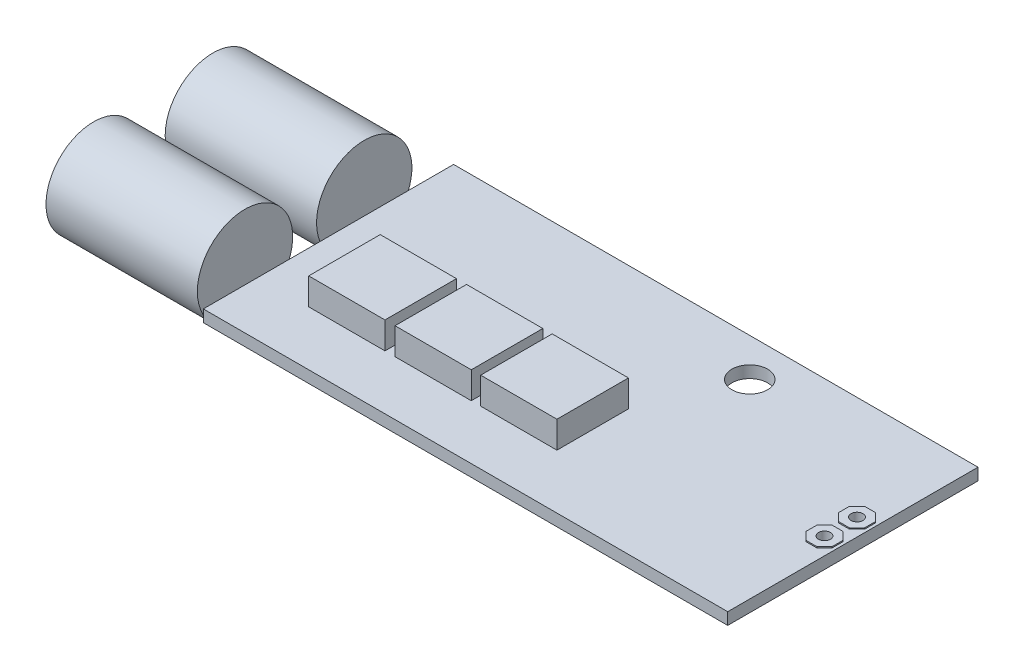
from build123d import *

# Parameters (mm, degrees)
SKETCH_1_W               = 44
SKETCH_1_H               = 21
EXTRUDE_1_DEPTH          = 1
EXTRUDE_3_DEPTH          = 0.1
SKETCH_2_R               = 1.5
SKETCH_2_R_2             = 0.5
CUT_EXTRUDE_1_DEPTH      = 1
CUT_EXTRUDE_1_DEPTH_BACK = 1
SKETCH_3_W               = 6.4
SKETCH_3_H               = 6
EXTRUDE_2_DEPTH          = 2.25
EXTRUDE_2_DEPTH_BACK     = 3.25
EXTRUDE_START            = 2
SKETCH_5_R               = 4
EXTRUDE_4_DEPTH          = 12.7
EXTRUDE_4_2_DEPTH        = 12.7


with BuildPart() as part:
    # Эскиз1 → Бобышка-Вытянуть1 (new body)
    with BuildSketch(Plane(origin=(0, 0, 0), x_dir=(1, 0, 0), z_dir=(0, 1, 0))):
        with Locations((22, -10.5)):
            Rectangle(SKETCH_1_W, SKETCH_1_H)
    extrude(amount=EXTRUDE_1_DEPTH)

    # Эскиз4 → Бобышка-Вытянуть3 (add)
    with BuildSketch(Plane(origin=(0, 1, 0), x_dir=(1, 0, 0), z_dir=(0, 1, 0))):
        Polygon((43.75, -8.344365081), (43.105634919, -7.7), (42.194365081, -7.7), (41.55, -8.344365081), (41.55, -9.255634919), (42.194365081, -9.9), (43.105634919, -9.9), (43.75, -9.255634919), align=None)
        Polygon((41.55, -11.074365081), (41.55, -11.985634919), (42.194365081, -12.63), (43.105634919, -12.63), (43.75, -11.985634919), (43.75, -11.074365081), (43.105634919, -10.43), (42.194365081, -10.43), align=None)
    extrude(amount=EXTRUDE_3_DEPTH)

    # Эскиз2 → Вырез-Вытянуть1 (cut, two sides)
    with BuildSketch(Plane(origin=(0, 1, 0), x_dir=(1, 0, 0), z_dir=(0, 1, 0))) as cut_extrude_1_sk:
        with Locations(Location((28.05, -3.2, 0), (0, 0, 270))):  # turned: the seam where the file's is
            Circle(SKETCH_2_R)
        with Locations(Location((42.65, -8.8, 0), (0, 0, 270))):  # turned: the seam where the file's is
            Circle(SKETCH_2_R_2)
        with Locations(Location((42.65, -11.53, 0), (0, 0, 270))):  # turned: the seam where the file's is
            Circle(SKETCH_2_R_2)
    extrude(amount=CUT_EXTRUDE_1_DEPTH, mode=Mode.SUBTRACT)
    extrude(cut_extrude_1_sk.sketch, amount=-CUT_EXTRUDE_1_DEPTH_BACK, mode=Mode.SUBTRACT)

    # Эскиз3 → Бобышка-Вытянуть2 (add, two sides)
    with BuildSketch(Plane(origin=(0, 1, 0), x_dir=(1, 0, 0), z_dir=(0, 1, 0))) as extrude_2_sk:
        with Locations((7.471, -13.429)):
            Rectangle(SKETCH_3_W, SKETCH_3_H)
        with Locations((14.714, -13.429)):
            Rectangle(SKETCH_3_W, SKETCH_3_H)
        with Locations((21.9, -13.429)):
            Rectangle(SKETCH_3_W, SKETCH_3_H)
    extrude(amount=EXTRUDE_2_DEPTH)
    extrude(extrude_2_sk.sketch, amount=-EXTRUDE_2_DEPTH_BACK)


with BuildPart() as body_2:
    # Эскиз5 → Бобышка-Вытянуть4 (new body)
    with BuildSketch(Plane.ZY.offset(EXTRUDE_START)):
        with Locations((5.5, 0.5)):
            Circle(SKETCH_5_R)
    extrude(amount=EXTRUDE_4_DEPTH)


with BuildPart() as body_3:
    # Эскиз5 → Extrude 4 2 (new body)
    with BuildSketch(Plane.ZY.offset(EXTRUDE_START)):
        with Locations((15.5, 0.5)):
            Circle(SKETCH_5_R)
    extrude(amount=EXTRUDE_4_2_DEPTH)


solid = Compound([part.part, body_2.part, body_3.part])
